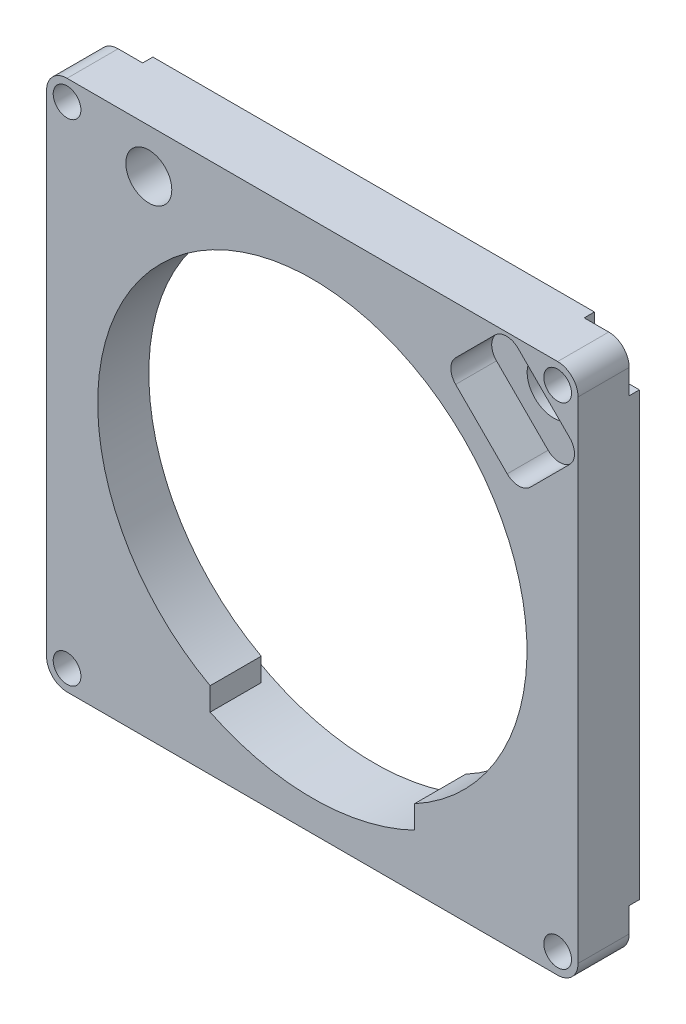
from build123d import *

# Parameters (mm, degrees)
BOSS_EXTRUDE1_DEPTH      = 7.9375
SKETCH2_R                = 36.5125
BOSS_EXTRUDE2_DEPTH      = 1.5875
F_6_CLEARANCE_HOLE1_D    = 4.3053
SKETCH5_R                = 3.57124
CUT_EXTRUDE1_DEPTH       = 7.9375
CUT_EXTRUDE2_REACH       = 3.588
SKETCH6_R                = 2.1
CUT_EXTRUDE3_DEPTH       = 6.35
F_5_16_CLEARANCE_HOLE1_D = 8.2042


with BuildPart() as part:
    # Sketch1 → Boss-Extrude1 (new body)
    with BuildSketch(Plane.XY):
        with BuildLine():
            Line((-38.1, -41.275), (38.1, -41.275))
            ThreePointArc((38.1, -41.275), (40.34506403, -40.34506403), (41.275, -38.1))
            Line((41.275, -38.1), (41.275, 38.1))
            ThreePointArc((41.275, 38.1), (40.34506403, 40.34506403), (38.1, 41.275))
            Line((38.1, 41.275), (-38.1, 41.275))
            ThreePointArc((-38.1, 41.275), (-40.34506403, 40.34506403), (-41.275, 38.1))
            Line((-41.275, 38.1), (-41.275, -38.1))
            ThreePointArc((-41.275, -38.1), (-40.34506403, -40.34506403), (-38.1, -41.275))
        make_face()
        with BuildLine():
            Line((15.875, -29.315069184), (15.875, -32.880800344))
            ThreePointArc((15.875, -32.880800344), (0, -36.5125), (-15.875, -32.880800344))
            Line((-15.875, -32.880800344), (-15.875, -29.315069184))
            ThreePointArc((-15.875, -29.315069184), (0, 33.3375), (15.875, -29.315069184))
        make_face(mode=Mode.SUBTRACT)
    extrude(amount=-BOSS_EXTRUDE1_DEPTH)

    # Sketch2 → Boss-Extrude2 (add)
    with BuildSketch(Plane(origin=(0, 0, -7.9375), x_dir=(-1, 0, 0), z_dir=(0, 0, -1))):
        with BuildLine():
            Line((-34.290000001, -38.1), (-34.290000001, -41.275))
            Line((-34.290000001, -41.275), (34.289999999, -41.275))
            Line((34.289999999, -41.275), (34.289999999, -38.1))
            ThreePointArc((34.289999999, -38.1), (35.405923163, -35.405923164), (38.099999999, -34.29))
            Line((38.099999999, -34.29), (41.274999999, -34.29))
            Line((41.274999999, -34.29), (41.274999999, 34.29))
            Line((41.274999999, 34.29), (38.099999999, 34.29))
            ThreePointArc((38.099999999, 34.29), (35.405923163, 35.405923164), (34.289999999, 38.1))
            Line((34.289999999, 38.1), (34.289999999, 41.275))
            Line((34.289999999, 41.275), (-34.290000001, 41.275))
            Line((-34.290000001, 41.275), (-34.290000001, 38.1))
            ThreePointArc((-34.290000001, 38.1), (-35.405923165, 35.405923164), (-38.100000001, 34.29))
            Line((-38.100000001, 34.29), (-41.275000001, 34.29))
            Line((-41.275000001, 34.29), (-41.275000001, -34.29))
            Line((-41.275000001, -34.29), (-38.100000001, -34.29))
            ThreePointArc((-38.100000001, -34.29), (-35.405923165, -35.405923164), (-34.290000001, -38.1))
        make_face()
        Circle(SKETCH2_R, mode=Mode.SUBTRACT)
    extrude(amount=BOSS_EXTRUDE2_DEPTH)

    # #6 Clearance Hole1 (through all)
    with Locations(Plane(origin=(0, 0, -7.9375), x_dir=(-1, 0, 0), z_dir=(0, 0, -1))):
        with Locations((-38.1, 38.1), (38.099999999, 38.1), (38.1, -38.1), (-38.1, -38.1)):
            Hole(F_6_CLEARANCE_HOLE1_D / 2)

    # Sketch5 → Cut-Extrude1 (cut)
    with BuildSketch(Plane.XY):
        with Locations((-25.4, 34.417)):
            Circle(SKETCH5_R)
    extrude(amount=-CUT_EXTRUDE1_DEPTH, mode=Mode.SUBTRACT)

    # Sketch6 → Cut-Extrude2 (cut, up to next)
    with BuildSketch(Plane.XY.offset(-7.9375), mode=Mode.PRIVATE) as cut_extrude2_sk1:
        with Locations((-25.4, 34.417)):
            Circle(SKETCH6_R)
    cut_extrude2_tool1 = extrude(cut_extrude2_sk1.sketch, amount=-CUT_EXTRUDE2_REACH, mode=Mode.PRIVATE) & part.part
    add(cut_extrude2_tool1.solids().sort_by_distance((-25.4, 34.417, -7.9375))[0], mode=Mode.SUBTRACT)

    # Sketch7 → Cut-Extrude3 (cut)
    with BuildSketch(Plane.XY):
        with BuildLine():
            Line((22.254952032, 30.270714503), (30.270714503, 22.254952032))
            ThreePointArc((30.270714503, 22.254952032), (32.066765727, 21.511003256), (33.862816952, 22.254952032))
            Line((33.862816952, 22.254952032), (39.975047968, 28.367183048))
            ThreePointArc((39.975047968, 28.367183048), (40.718996744, 30.163234273), (39.975047968, 31.959285497))
            Line((39.975047968, 31.959285497), (31.959285497, 39.975047968))
            ThreePointArc((31.959285497, 39.975047968), (30.163234273, 40.718996744), (28.367183048, 39.975047968))
            Line((28.367183048, 39.975047968), (22.254952032, 33.862816952))
            ThreePointArc((22.254952032, 33.862816952), (21.511003256, 32.066765727), (22.254952032, 30.270714503))
        make_face()
    extrude(amount=-CUT_EXTRUDE3_DEPTH, mode=Mode.SUBTRACT)

    # 5/16 Clearance Hole1 (through all)
    with Locations(Plane(origin=(0, 0, -9.525), x_dir=(-1, 0, 0), z_dir=(0, 0, -1))):
        with Locations((-31.115, 31.115)):
            Hole(F_5_16_CLEARANCE_HOLE1_D / 2)


solid = part.part
